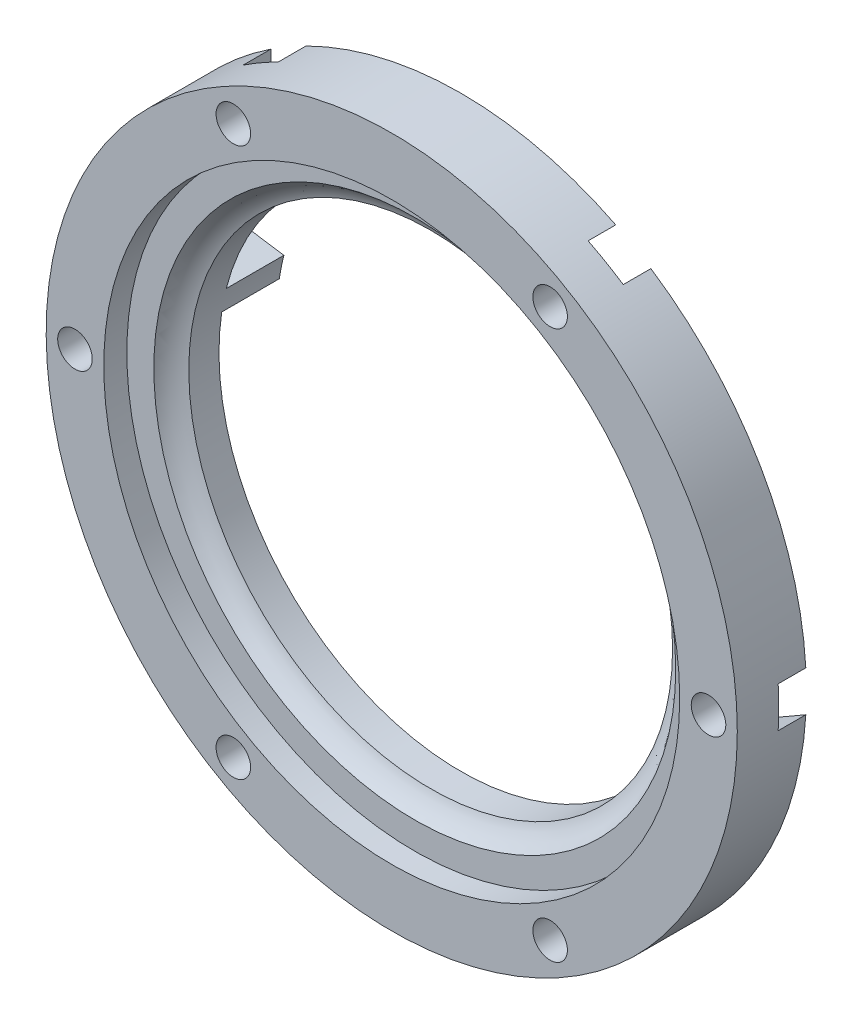
from build123d import *

# Parameters (mm, degrees)
SCHIZZO1_R                   = 30
SCHIZZO1_R_2                 = 21
ESTRUSIONE_ESTRUSIONE1_DEPTH = 4
SCHIZZO2_R                   = 3.05
SCHIZZO3_R                   = 30
SCHIZZO3_R_2                 = 25
ESTRUSIONE_ESTRUSIONE2_DEPTH = 2
TAGLIO_ESTRUSIONE1_START     = -1
SCHIZZO4_R                   = 1.5
TAGLIO_ESTRUSIONE1_DEPTH     = 8
TAGLIO_ESTRUSIONE2_DEPTH     = 2.4
RIPETIZIONECIRCOLARE1_COUNT  = 6
ESTRUSIONE_ESTRUSIONE3_DEPTH = 5


with BuildPart() as part:
    # Schizzo1 → Estrusione-Estrusione1 (new body)
    with BuildSketch(Plane.XY):
        Circle(SCHIZZO1_R)
        Circle(SCHIZZO1_R_2, mode=Mode.SUBTRACT)
    extrude(amount=ESTRUSIONE_ESTRUSIONE1_DEPTH)

    # Schizzo2 → Taglia-Rivoluzione1 (revolve, cut)
    with BuildSketch(Plane(origin=(0, 0, 0), x_dir=(0, 0, -1), z_dir=(1, 0, 0))):
        with Locations((-5.5, 20)):
            Circle(SCHIZZO2_R)
    revolve(axis=Axis((0, 0, 4), (0, 0, -1)), mode=Mode.SUBTRACT)

    # Schizzo3 → Estrusione-Estrusione2 (add)
    with BuildSketch(Plane.XY.offset(4)):
        Circle(SCHIZZO3_R)
        Circle(SCHIZZO3_R_2, mode=Mode.SUBTRACT)
    extrude(amount=ESTRUSIONE_ESTRUSIONE2_DEPTH)

    # Schizzo4 → Taglio-Estrusione1 (cut)
    with BuildSketch(Plane.XY.offset(TAGLIO_ESTRUSIONE1_START)):
        with Locations((-27.5, 0)):
            Circle(SCHIZZO4_R)
    taglio_estrusione1 = extrude(amount=TAGLIO_ESTRUSIONE1_DEPTH, mode=Mode.SUBTRACT)

    # Schizzo5 → Taglio-Estrusione2 (cut)
    with BuildSketch(Plane(origin=(0, 0, 0), x_dir=(-1, 0, 0), z_dir=(0, 0, -1))):
        Polygon((30.25, 1.58771324), (27.5, 3.175426481), (24.75, 1.58771324), (24.75, -1.58771324), (27.5, -3.175426481), (30.25, -1.58771324), align=None)
    taglio_estrusione2 = extrude(amount=-TAGLIO_ESTRUSIONE2_DEPTH, mode=Mode.SUBTRACT)

    # RipetizioneCircolare1: Taglio-Estrusione1, Taglio-Estrusione2 ×6 about axis
    ripetizionecircolare1_axis = Axis((0, 0, 0), (0, 0, 1))
    for i in range(1, RIPETIZIONECIRCOLARE1_COUNT):
        add(taglio_estrusione1.rotate(ripetizionecircolare1_axis, i * 360 / RIPETIZIONECIRCOLARE1_COUNT), mode=Mode.SUBTRACT)
        add(taglio_estrusione2.rotate(ripetizionecircolare1_axis, i * 360 / RIPETIZIONECIRCOLARE1_COUNT), mode=Mode.SUBTRACT)

    # Schizzo6 → Estrusione-Estrusione3 (add)
    with BuildSketch(Plane(origin=(0, 0, 0), x_dir=(-1, 0, 0), z_dir=(0, 0, -1))):
        with BuildLine():
            Line((20.760752105, 3.160881527), (29.658217293, 4.515545038))
            ThreePointArc((29.658217293, 4.515545038), (29.491115616, 5.50219045), (29.291200414, 6.482713806))
            Line((29.291200414, 6.482713806), (20.365348226, 5.123728295))
            ThreePointArc((20.365348226, 5.123728295), (20.586457295, 4.147020139), (20.760752105, 3.160881527))
        make_face()
    extrude(amount=ESTRUSIONE_ESTRUSIONE3_DEPTH)


solid = part.part
